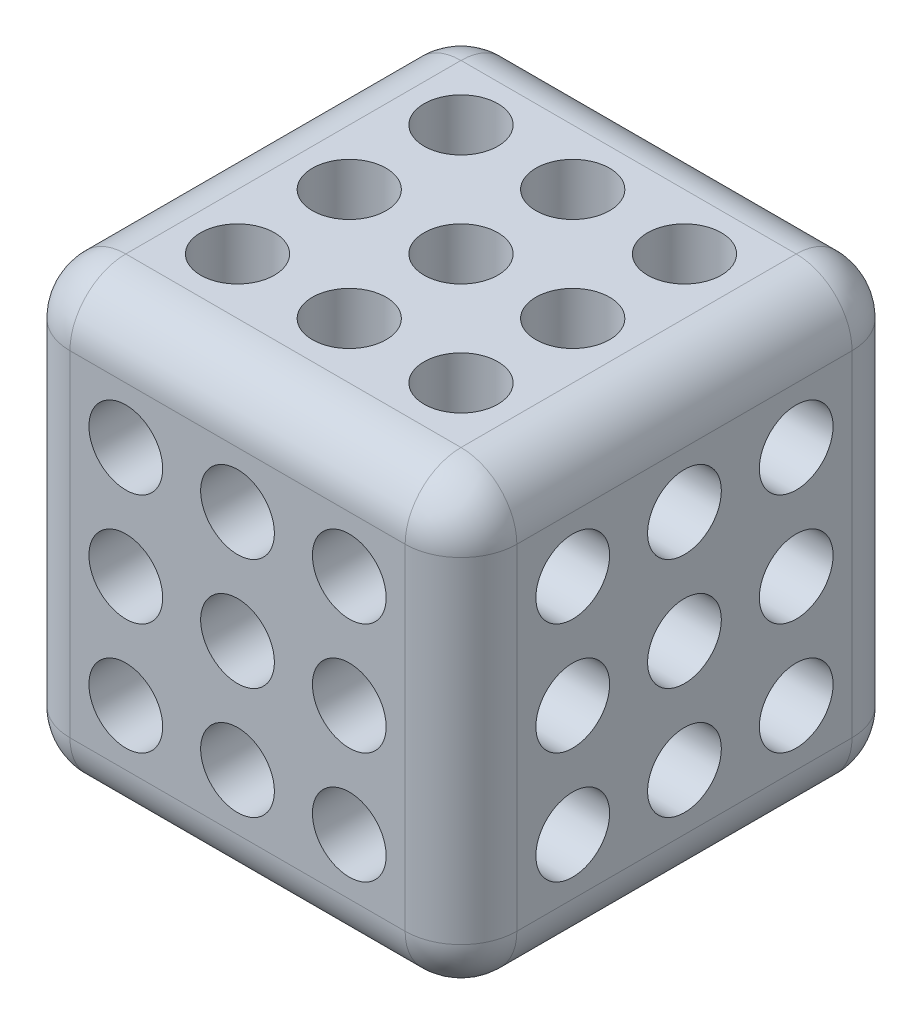
from build123d import *

# Parameters (mm, degrees)
BOSS_EXTRU_1_DEPTH         = 10
TROU_TARAUD_M41_AT_2_COUNT = 2
TROU_TARAUD_M41_AT_2_PITCH = 5.000000000000002
TROU_TARAUD_M41_AT_3_COUNT = 2
TROU_TARAUD_M41_AT_3_PITCH = 10.000000000000004
TROU_TARAUD_M41_AT_4_COUNT = 2
TROU_TARAUD_M41_AT_4_PITCH = 11.180339887498949
TROU_TARAUD_M41_AT_5_COUNT = 2
TROU_TARAUD_M41_AT_5_PITCH = 7.071067811865475
TROU_TARAUD_M41_AT_6_COUNT = 2
TROU_TARAUD_M41_AT_6_PITCH = 4.999999999999997
TROU_TARAUD_M41_AT_7_COUNT = 2
TROU_TARAUD_M41_AT_7_PITCH = 9.999999999999995
TROU_TARAUD_M41_AT_8_COUNT = 2
TROU_TARAUD_M41_AT_8_PITCH = 11.180339887498942
TROU_TARAUD_M41_AT_9_COUNT = 2
TROU_TARAUD_M41_AT_9_PITCH = 14.14213562373095
TROU_TARAUD_M43_AT_2_COUNT = 2
TROU_TARAUD_M43_AT_2_PITCH = 7.071067811865478
TROU_TARAUD_M43_AT_3_COUNT = 2
TROU_TARAUD_M43_AT_3_PITCH = 7.071067811865479
TROU_TARAUD_M43_AT_4_COUNT = 2
TROU_TARAUD_M43_AT_4_PITCH = 7.071067811865476
TROU_TARAUD_M43_AT_5_COUNT = 2
TROU_TARAUD_M43_AT_5_PITCH = 7.07106781186548
TROU_TARAUD_M43_AT_6_COUNT = 2
TROU_TARAUD_M43_AT_6_PITCH = 5
TROU_TARAUD_M43_AT_7_COUNT = 2
TROU_TARAUD_M43_AT_7_PITCH = 5
TROU_TARAUD_M43_AT_8_COUNT = 2
TROU_TARAUD_M43_AT_8_PITCH = 5.000000000000007
TROU_TARAUD_M43_AT_9_COUNT = 2
TROU_TARAUD_M43_AT_9_PITCH = 4.9999999999999964
TROU_TARAUD_M44_AT_2_COUNT = 2
TROU_TARAUD_M44_AT_2_PITCH = 7.071067811865476
TROU_TARAUD_M44_AT_3_COUNT = 2
TROU_TARAUD_M44_AT_3_PITCH = 7.071067811865477
TROU_TARAUD_M44_AT_4_COUNT = 2
TROU_TARAUD_M44_AT_4_PITCH = 7.071067811865475
TROU_TARAUD_M44_AT_5_COUNT = 2
TROU_TARAUD_M44_AT_5_PITCH = 7.071067811865478
TROU_TARAUD_M44_AT_6_COUNT = 2
TROU_TARAUD_M44_AT_6_PITCH = 5.000000000000001
TROU_TARAUD_M44_AT_7_COUNT = 2
TROU_TARAUD_M44_AT_7_PITCH = 5
TROU_TARAUD_M44_AT_8_COUNT = 2
TROU_TARAUD_M44_AT_8_PITCH = 5.000000000000008
TROU_TARAUD_M44_AT_9_COUNT = 2
TROU_TARAUD_M44_AT_9_PITCH = 4.9999999999999964
CONG_1_R                   = 2.5


with BuildPart() as part:
    # Esquisse1 → Boss.-Extru.1 (new, symmetric)
    with BuildSketch(Plane(origin=(0, 0, 0), x_dir=(0, 0, -1), z_dir=(1, 0, 0))):
        Polygon((10.000000000000002, -10), (-9.999999999999998, -10.000000000000002), (-9.999999999999998, 9.999999999999998), (10.000000000000002, 10), align=None)
    extrude(amount=BOSS_EXTRU_1_DEPTH, both=True)

    # Esquisse3 → Trou taraudé M41 (revolve, cut)
    with BuildSketch(Plane(origin=(10, 4.999999999999997, 5.000000000000002), x_dir=(0, 0, -1), z_dir=(0, 1, 0))):
        Polygon((0, 0), (-2.69e-15, 10.991420021395477), (1.6499999999999946, 10.000000000000002), (1.64999999999999, -1.35e-15), align=None)
    trou_taraud_m41 = revolve(axis=Axis((16.34999999999999, 4.999999999999997, 5.000000000000002), (-1, 0, 0)), mode=Mode.SUBTRACT)

    # Trou taraudé M41 at 2: Trou taraudé M41 ×2
    with Locations(*[(0, 0, -i * TROU_TARAUD_M41_AT_2_PITCH) for i in range(1, TROU_TARAUD_M41_AT_2_COUNT)]):
        add(trou_taraud_m41, mode=Mode.SUBTRACT)

    # Trou taraudé M41 at 3: Trou taraudé M41 ×2
    with Locations(*[(0, 0, -i * TROU_TARAUD_M41_AT_3_PITCH) for i in range(1, TROU_TARAUD_M41_AT_3_COUNT)]):
        add(trou_taraud_m41, mode=Mode.SUBTRACT)

    # Trou taraudé M41 at 4: Trou taraudé M41 ×2
    with Locations(*[Vector(0, -0.4472135954999577, -0.894427190999916) * (i * TROU_TARAUD_M41_AT_4_PITCH) for i in range(1, TROU_TARAUD_M41_AT_4_COUNT)]):
        add(trou_taraud_m41, mode=Mode.SUBTRACT)

    # Trou taraudé M41 at 5: Trou taraudé M41 ×2
    with Locations(*[Vector(0, -0.7071067811865472, -0.7071067811865478) * (i * TROU_TARAUD_M41_AT_5_PITCH) for i in range(1, TROU_TARAUD_M41_AT_5_COUNT)]):
        add(trou_taraud_m41, mode=Mode.SUBTRACT)

    # Trou taraudé M41 at 6: Trou taraudé M41 ×2
    with Locations(*[(0, -i * TROU_TARAUD_M41_AT_6_PITCH, 0) for i in range(1, TROU_TARAUD_M41_AT_6_COUNT)]):
        add(trou_taraud_m41, mode=Mode.SUBTRACT)

    # Trou taraudé M41 at 7: Trou taraudé M41 ×2
    with Locations(*[(0, -i * TROU_TARAUD_M41_AT_7_PITCH, 0) for i in range(1, TROU_TARAUD_M41_AT_7_COUNT)]):
        add(trou_taraud_m41, mode=Mode.SUBTRACT)

    # Trou taraudé M41 at 8: Trou taraudé M41 ×2
    with Locations(*[Vector(0, -0.8944271909999157, -0.44721359549995837) * (i * TROU_TARAUD_M41_AT_8_PITCH) for i in range(1, TROU_TARAUD_M41_AT_8_COUNT)]):
        add(trou_taraud_m41, mode=Mode.SUBTRACT)

    # Trou taraudé M41 at 9: Trou taraudé M41 ×2
    with Locations(*[Vector(0, -0.7071067811865472, -0.7071067811865478) * (i * TROU_TARAUD_M41_AT_9_PITCH) for i in range(1, TROU_TARAUD_M41_AT_9_COUNT)]):
        add(trou_taraud_m41, mode=Mode.SUBTRACT)

    # Esquisse10 → Trou taraudé M43 (revolve, cut)
    with BuildSketch(Plane(origin=(0, 0, 9.999999999999998), x_dir=(0, -1, 0), z_dir=(1, 0, 0))):
        Polygon((0, 0), (-2.69e-15, 10.991420021395475), (1.6499999999999975, 10), (1.64999999999999, -1.35e-15), align=None)
    trou_taraud_m43 = revolve(axis=Axis((0, 0, 16.349999999999987), (0, 0, -1)), mode=Mode.SUBTRACT)

    # Trou taraudé M43 at 2: Trou taraudé M43 ×2
    with Locations(*[Vector(0.707106781186547, 0.707106781186548, 0) * (i * TROU_TARAUD_M43_AT_2_PITCH) for i in range(1, TROU_TARAUD_M43_AT_2_COUNT)]):
        add(trou_taraud_m43, mode=Mode.SUBTRACT)

    # Trou taraudé M43 at 3: Trou taraudé M43 ×2
    with Locations(*[Vector(-0.7071067811865467, -0.7071067811865483, 0) * (i * TROU_TARAUD_M43_AT_3_PITCH) for i in range(1, TROU_TARAUD_M43_AT_3_COUNT)]):
        add(trou_taraud_m43, mode=Mode.SUBTRACT)

    # Trou taraudé M43 at 4: Trou taraudé M43 ×2
    with Locations(*[Vector(-0.7071067811865471, 0.7071067811865479, 0) * (i * TROU_TARAUD_M43_AT_4_PITCH) for i in range(1, TROU_TARAUD_M43_AT_4_COUNT)]):
        add(trou_taraud_m43, mode=Mode.SUBTRACT)

    # Trou taraudé M43 at 5: Trou taraudé M43 ×2
    with Locations(*[Vector(0.707106781186547, -0.707106781186548, 0) * (i * TROU_TARAUD_M43_AT_5_PITCH) for i in range(1, TROU_TARAUD_M43_AT_5_COUNT)]):
        add(trou_taraud_m43, mode=Mode.SUBTRACT)

    # Trou taraudé M43 at 6: Trou taraudé M43 ×2
    with Locations(*[(0, i * TROU_TARAUD_M43_AT_6_PITCH, 0) for i in range(1, TROU_TARAUD_M43_AT_6_COUNT)]):
        add(trou_taraud_m43, mode=Mode.SUBTRACT)

    # Trou taraudé M43 at 7: Trou taraudé M43 ×2
    with Locations(*[(i * TROU_TARAUD_M43_AT_7_PITCH, 0, 0) for i in range(1, TROU_TARAUD_M43_AT_7_COUNT)]):
        add(trou_taraud_m43, mode=Mode.SUBTRACT)

    # Trou taraudé M43 at 8: Trou taraudé M43 ×2
    with Locations(*[(0, -i * TROU_TARAUD_M43_AT_8_PITCH, 0) for i in range(1, TROU_TARAUD_M43_AT_8_COUNT)]):
        add(trou_taraud_m43, mode=Mode.SUBTRACT)

    # Trou taraudé M43 at 9: Trou taraudé M43 ×2
    with Locations(*[(-i * TROU_TARAUD_M43_AT_9_PITCH, 0, 0) for i in range(1, TROU_TARAUD_M43_AT_9_COUNT)]):
        add(trou_taraud_m43, mode=Mode.SUBTRACT)

    # Esquisse12 → Trou taraudé M44 (revolve, cut)
    with BuildSketch(Plane(origin=(0, -10.000000000000002, -8.7e-16), x_dir=(0, 1.2e-16, -1), z_dir=(1, 0, 0))):
        Polygon((0, 0), (-2.69e-15, 10.991420021395474), (1.6499999999999946, 10.000000000000002), (1.64999999999999, -1.35e-15), align=None)
    trou_taraud_m44 = revolve(axis=Axis((0, -16.349999999999994, -1.6e-15), (0, 1, 1.2e-16)), mode=Mode.SUBTRACT)

    # Trou taraudé M44 at 2: Trou taraudé M44 ×2
    with Locations(*[Vector(-0.7071067811865472, 0, -0.7071067811865479) * (i * TROU_TARAUD_M44_AT_2_PITCH) for i in range(1, TROU_TARAUD_M44_AT_2_COUNT)]):
        add(trou_taraud_m44, mode=Mode.SUBTRACT)

    # Trou taraudé M44 at 3: Trou taraudé M44 ×2
    with Locations(*[Vector(0.7071067811865468, 0, 0.7071067811865482) * (i * TROU_TARAUD_M44_AT_3_PITCH) for i in range(1, TROU_TARAUD_M44_AT_3_COUNT)]):
        add(trou_taraud_m44, mode=Mode.SUBTRACT)

    # Trou taraudé M44 at 4: Trou taraudé M44 ×2
    with Locations(*[Vector(0.7071067811865474, 0, -0.7071067811865477) * (i * TROU_TARAUD_M44_AT_4_PITCH) for i in range(1, TROU_TARAUD_M44_AT_4_COUNT)]):
        add(trou_taraud_m44, mode=Mode.SUBTRACT)

    # Trou taraudé M44 at 5: Trou taraudé M44 ×2
    with Locations(*[Vector(-0.7071067811865472, 0, 0.7071067811865479) * (i * TROU_TARAUD_M44_AT_5_PITCH) for i in range(1, TROU_TARAUD_M44_AT_5_COUNT)]):
        add(trou_taraud_m44, mode=Mode.SUBTRACT)

    # Trou taraudé M44 at 6: Trou taraudé M44 ×2
    with Locations(*[(0, 0, -i * TROU_TARAUD_M44_AT_6_PITCH) for i in range(1, TROU_TARAUD_M44_AT_6_COUNT)]):
        add(trou_taraud_m44, mode=Mode.SUBTRACT)

    # Trou taraudé M44 at 7: Trou taraudé M44 ×2
    with Locations(*[(-i * TROU_TARAUD_M44_AT_7_PITCH, 0, 0) for i in range(1, TROU_TARAUD_M44_AT_7_COUNT)]):
        add(trou_taraud_m44, mode=Mode.SUBTRACT)

    # Trou taraudé M44 at 8: Trou taraudé M44 ×2
    with Locations(*[(0, 0, i * TROU_TARAUD_M44_AT_8_PITCH) for i in range(1, TROU_TARAUD_M44_AT_8_COUNT)]):
        add(trou_taraud_m44, mode=Mode.SUBTRACT)

    # Trou taraudé M44 at 9: Trou taraudé M44 ×2
    with Locations(*[(i * TROU_TARAUD_M44_AT_9_PITCH, 0, 0) for i in range(1, TROU_TARAUD_M44_AT_9_COUNT)]):
        add(trou_taraud_m44, mode=Mode.SUBTRACT)

    # Congé1
    cong_1_edges = [part.edges().sort_by_distance(p)[0] for p in [
        (10, 0, -10.000000000000002),
        (10, 10, -1.78e-15),
        (10, -1.78e-15, 9.999999999999998),
        (-10, 10, -1.78e-15),
        (-10, 0, -10.000000000000002),
        (-10, -10, -1.78e-15),
        (-10, -1.78e-15, 9.999999999999998),
        (0, 9.999999999999998, 9.999999999999998),
        (0, 10, -10.000000000000002),
        (0, -10, -10.000000000000002),
        (0, -10.000000000000002, 9.999999999999998),
        (10, -10, -1.78e-15),
    ]]
    fillet(cong_1_edges, radius=CONG_1_R)

    # Symétrie1: Trou taraudé M41 across plane
    add(trou_taraud_m41.mirror(Plane(origin=(0, 0, 0), x_dir=(0, 0, 1), z_dir=(1, 0, 0))), mode=Mode.SUBTRACT)

    # Symétrie1 copy 1 sketch → Symétrie1 copy 1 (revolve, cut)
    with BuildSketch(Plane(origin=(-10, 5, 0), x_dir=(0, 0, -1), z_dir=(0, 1, 0))):
        Polygon((0, 0), (-2.69e-15, -10.991420021395477), (1.6499999999999946, -10.000000000000002), (1.64999999999999, 1.35e-15), align=None)
    revolve(axis=Axis((-16.34999999999999, 5, 0), (-1, 0, 0)), mode=Mode.SUBTRACT)

    # Symétrie1 copy 2 sketch → Symétrie1 copy 2 (revolve, cut)
    with BuildSketch(Plane(origin=(-10, 4.999999999999997, -5.000000000000002), x_dir=(0, 0, -1), z_dir=(0, 1, 0))):
        Polygon((0, 0), (-2.69e-15, -10.991420021395477), (1.6499999999999946, -10.000000000000002), (1.64999999999999, 1.35e-15), align=None)
    revolve(axis=Axis((-16.34999999999999, 4.999999999999997, -5.000000000000002), (-1, 0, 0)), mode=Mode.SUBTRACT)

    # Symétrie1 copy 3 sketch → Symétrie1 copy 3 (revolve, cut)
    with BuildSketch(Plane(origin=(-10, 0, -5), x_dir=(0, 0, -1), z_dir=(0, 1, 0))):
        Polygon((0, 0), (-2.69e-15, -10.991420021395477), (1.6499999999999946, -10.000000000000002), (1.64999999999999, 1.35e-15), align=None)
    revolve(axis=Axis((-16.34999999999999, 0, -5), (-1, 0, 0)), mode=Mode.SUBTRACT)

    # Symétrie1 copy 4 sketch → Symétrie1 copy 4 (revolve, cut)
    with BuildSketch(Plane(origin=(-10, 0, 0), x_dir=(0, 0, -1), z_dir=(0, 1, 0))):
        Polygon((0, 0), (-2.69e-15, -10.991420021395477), (1.6499999999999946, -10.000000000000002), (1.64999999999999, 1.35e-15), align=None)
    revolve(axis=Axis((-16.34999999999999, 0, 0), (-1, 0, 0)), mode=Mode.SUBTRACT)

    # Symétrie1 copy 5 sketch → Symétrie1 copy 5 (revolve, cut)
    with BuildSketch(Plane(origin=(-10, 0, 5.000000000000002), x_dir=(0, 0, -1), z_dir=(0, 1, 0))):
        Polygon((0, 0), (-2.69e-15, -10.991420021395477), (1.6499999999999946, -10.000000000000002), (1.64999999999999, 1.35e-15), align=None)
    revolve(axis=Axis((-16.34999999999999, 0, 5.000000000000002), (-1, 0, 0)), mode=Mode.SUBTRACT)

    # Symétrie1 copy 6 sketch → Symétrie1 copy 6 (revolve, cut)
    with BuildSketch(Plane(origin=(-10, -4.999999999999997, 5.000000000000002), x_dir=(0, 0, -1), z_dir=(0, 1, 0))):
        Polygon((0, 0), (-2.69e-15, -10.991420021395477), (1.6499999999999946, -10.000000000000002), (1.64999999999999, 1.35e-15), align=None)
    revolve(axis=Axis((-16.34999999999999, -4.999999999999997, 5.000000000000002), (-1, 0, 0)), mode=Mode.SUBTRACT)

    # Symétrie1 copy 7 sketch → Symétrie1 copy 7 (revolve, cut)
    with BuildSketch(Plane(origin=(-10, -4.999999999999996, 0), x_dir=(0, 0, -1), z_dir=(0, 1, 0))):
        Polygon((0, 0), (-2.69e-15, -10.991420021395477), (1.6499999999999946, -10.000000000000002), (1.64999999999999, 1.35e-15), align=None)
    revolve(axis=Axis((-16.34999999999999, -4.999999999999996, 0), (-1, 0, 0)), mode=Mode.SUBTRACT)

    # Symétrie1 copy 8 sketch → Symétrie1 copy 8 (revolve, cut)
    with BuildSketch(Plane(origin=(-10, -4.999999999999997, -5.000000000000002), x_dir=(0, 0, -1), z_dir=(0, 1, 0))):
        Polygon((0, 0), (-2.69e-15, -10.991420021395477), (1.6499999999999946, -10.000000000000002), (1.64999999999999, 1.35e-15), align=None)
    revolve(axis=Axis((-16.34999999999999, -4.999999999999997, -5.000000000000002), (-1, 0, 0)), mode=Mode.SUBTRACT)

    # Symétrie2: Trou taraudé M43 across plane
    add(trou_taraud_m43.mirror(Plane.XY), mode=Mode.SUBTRACT)

    # Symétrie2 copy 1 sketch → Symétrie2 copy 1 (revolve, cut)
    with BuildSketch(Plane(origin=(4.999999999999998, 5.000000000000005, -9.999999999999998), x_dir=(0, -1, 0), z_dir=(1, 0, 0))):
        Polygon((0, 0), (-2.69e-15, -10.991420021395475), (1.6499999999999975, -10), (1.64999999999999, 1.35e-15), align=None)
    revolve(axis=Axis((4.999999999999998, 5.000000000000005, -16.349999999999987), (0, 0, -1)), mode=Mode.SUBTRACT)

    # Symétrie2 copy 2 sketch → Symétrie2 copy 2 (revolve, cut)
    with BuildSketch(Plane(origin=(-4.9999999999999964, -5.000000000000009, -9.999999999999998), x_dir=(0, -1, 0), z_dir=(1, 0, 0))):
        Polygon((0, 0), (-2.69e-15, -10.991420021395475), (1.6499999999999975, -10), (1.64999999999999, 1.35e-15), align=None)
    revolve(axis=Axis((-4.9999999999999964, -5.000000000000009, -16.349999999999987), (0, 0, -1)), mode=Mode.SUBTRACT)

    # Symétrie2 copy 3 sketch → Symétrie2 copy 3 (revolve, cut)
    with BuildSketch(Plane(origin=(-4.999999999999998, 5.0000000000000036, -9.999999999999998), x_dir=(0, -1, 0), z_dir=(1, 0, 0))):
        Polygon((0, 0), (-2.69e-15, -10.991420021395475), (1.6499999999999975, -10), (1.64999999999999, 1.35e-15), align=None)
    revolve(axis=Axis((-4.999999999999998, 5.0000000000000036, -16.349999999999987), (0, 0, -1)), mode=Mode.SUBTRACT)

    # Symétrie2 copy 4 sketch → Symétrie2 copy 4 (revolve, cut)
    with BuildSketch(Plane(origin=(5, -5.000000000000007, -9.999999999999998), x_dir=(0, -1, 0), z_dir=(1, 0, 0))):
        Polygon((0, 0), (-2.69e-15, -10.991420021395475), (1.6499999999999975, -10), (1.64999999999999, 1.35e-15), align=None)
    revolve(axis=Axis((5, -5.000000000000007, -16.349999999999987), (0, 0, -1)), mode=Mode.SUBTRACT)

    # Symétrie2 copy 5 sketch → Symétrie2 copy 5 (revolve, cut)
    with BuildSketch(Plane(origin=(9.2e-16, 5, -9.999999999999998), x_dir=(0, -1, 0), z_dir=(1, 0, 0))):
        Polygon((0, 0), (-2.69e-15, -10.991420021395475), (1.6499999999999975, -10), (1.64999999999999, 1.35e-15), align=None)
    revolve(axis=Axis((9.2e-16, 5, -16.349999999999987), (0, 0, -1)), mode=Mode.SUBTRACT)

    # Symétrie2 copy 6 sketch → Symétrie2 copy 6 (revolve, cut)
    with BuildSketch(Plane(origin=(5, -9.2e-16, -9.999999999999998), x_dir=(0, -1, 0), z_dir=(1, 0, 0))):
        Polygon((0, 0), (-2.69e-15, -10.991420021395475), (1.6499999999999975, -10), (1.64999999999999, 1.35e-15), align=None)
    revolve(axis=Axis((5, -9.2e-16, -16.349999999999987), (0, 0, -1)), mode=Mode.SUBTRACT)

    # Symétrie2 copy 7 sketch → Symétrie2 copy 7 (revolve, cut)
    with BuildSketch(Plane(origin=(3.47e-15, -5.000000000000007, -9.999999999999998), x_dir=(0, -1, 0), z_dir=(1, 0, 0))):
        Polygon((0, 0), (-2.69e-15, -10.991420021395475), (1.6499999999999975, -10), (1.64999999999999, 1.35e-15), align=None)
    revolve(axis=Axis((3.47e-15, -5.000000000000007, -16.349999999999987), (0, 0, -1)), mode=Mode.SUBTRACT)

    # Symétrie2 copy 8 sketch → Symétrie2 copy 8 (revolve, cut)
    with BuildSketch(Plane(origin=(-4.9999999999999964, -2.6e-15, -9.999999999999998), x_dir=(0, -1, 0), z_dir=(1, 0, 0))):
        Polygon((0, 0), (-2.69e-15, -10.991420021395475), (1.6499999999999975, -10), (1.64999999999999, 1.35e-15), align=None)
    revolve(axis=Axis((-4.9999999999999964, -2.6e-15, -16.349999999999987), (0, 0, -1)), mode=Mode.SUBTRACT)

    # Symétrie3: Trou taraudé M44 across plane
    add(trou_taraud_m44.mirror(Plane.ZX), mode=Mode.SUBTRACT)

    # Symétrie3 copy 1 sketch → Symétrie3 copy 1 (revolve, cut)
    with BuildSketch(Plane(origin=(-4.999999999999999, 10, -5.000000000000004), x_dir=(0, -1.2e-16, -1), z_dir=(1, 0, 0))):
        Polygon((0, 0), (-2.69e-15, -10.991420021395474), (1.6499999999999946, -10.000000000000002), (1.64999999999999, 1.35e-15), align=None)
    revolve(axis=Axis((-4.999999999999999, 16.349999999999994, -5.000000000000005), (0, 1, -1.2e-16)), mode=Mode.SUBTRACT)

    # Symétrie3 copy 2 sketch → Symétrie3 copy 2 (revolve, cut)
    with BuildSketch(Plane(origin=(4.9999999999999964, 10.000000000000004, 5.000000000000005), x_dir=(0, -1.2e-16, -1), z_dir=(1, 0, 0))):
        Polygon((0, 0), (-2.69e-15, -10.991420021395474), (1.6499999999999946, -10.000000000000002), (1.64999999999999, 1.35e-15), align=None)
    revolve(axis=Axis((4.9999999999999964, 16.349999999999994, 5.000000000000004), (0, 1, -1.2e-16)), mode=Mode.SUBTRACT)

    # Symétrie3 copy 3 sketch → Symétrie3 copy 3 (revolve, cut)
    with BuildSketch(Plane(origin=(4.999999999999998, 10, -5.000000000000002), x_dir=(0, -1.2e-16, -1), z_dir=(1, 0, 0))):
        Polygon((0, 0), (-2.69e-15, -10.991420021395474), (1.6499999999999946, -10.000000000000002), (1.64999999999999, 1.35e-15), align=None)
    revolve(axis=Axis((4.999999999999998, 16.349999999999994, -5.000000000000003), (0, 1, -1.2e-16)), mode=Mode.SUBTRACT)

    # Symétrie3 copy 4 sketch → Symétrie3 copy 4 (revolve, cut)
    with BuildSketch(Plane(origin=(-5, 10.000000000000004, 5.0000000000000036), x_dir=(0, -1.2e-16, -1), z_dir=(1, 0, 0))):
        Polygon((0, 0), (-2.69e-15, -10.991420021395474), (1.6499999999999946, -10.000000000000002), (1.64999999999999, 1.35e-15), align=None)
    revolve(axis=Axis((-5, 16.349999999999994, 5.000000000000003), (0, 1, -1.2e-16)), mode=Mode.SUBTRACT)

    # Symétrie3 copy 5 sketch → Symétrie3 copy 5 (revolve, cut)
    with BuildSketch(Plane(origin=(-9.2e-16, 10, -5.000000000000002), x_dir=(0, -1.2e-16, -1), z_dir=(1, 0, 0))):
        Polygon((0, 0), (-2.69e-15, -10.991420021395474), (1.6499999999999946, -10.000000000000002), (1.64999999999999, 1.35e-15), align=None)
    revolve(axis=Axis((-9.2e-16, 16.349999999999994, -5.000000000000003), (0, 1, -1.2e-16)), mode=Mode.SUBTRACT)

    # Symétrie3 copy 6 sketch → Symétrie3 copy 6 (revolve, cut)
    with BuildSketch(Plane(origin=(-5, 10.000000000000002, 5e-17), x_dir=(0, -1.2e-16, -1), z_dir=(1, 0, 0))):
        Polygon((0, 0), (-2.69e-15, -10.991420021395474), (1.6499999999999946, -10.000000000000002), (1.64999999999999, 1.35e-15), align=None)
    revolve(axis=Axis((-5, 16.349999999999994, -6.8e-16), (0, 1, -1.2e-16)), mode=Mode.SUBTRACT)

    # Symétrie3 copy 7 sketch → Symétrie3 copy 7 (revolve, cut)
    with BuildSketch(Plane(origin=(-3.47e-15, 10.000000000000004, 5.000000000000007), x_dir=(0, -1.2e-16, -1), z_dir=(1, 0, 0))):
        Polygon((0, 0), (-2.69e-15, -10.991420021395474), (1.6499999999999946, -10.000000000000002), (1.64999999999999, 1.35e-15), align=None)
    revolve(axis=Axis((-3.47e-15, 16.349999999999994, 5.000000000000006), (0, 1, -1.2e-16)), mode=Mode.SUBTRACT)

    # Symétrie3 copy 8 sketch → Symétrie3 copy 8 (revolve, cut)
    with BuildSketch(Plane(origin=(4.9999999999999964, 10.000000000000002, 1.73e-15), x_dir=(0, -1.2e-16, -1), z_dir=(1, 0, 0))):
        Polygon((0, 0), (-2.69e-15, -10.991420021395474), (1.6499999999999946, -10.000000000000002), (1.64999999999999, 1.35e-15), align=None)
    revolve(axis=Axis((4.9999999999999964, 16.349999999999994, 1e-15), (0, 1, -1.2e-16)), mode=Mode.SUBTRACT)


solid = part.part
